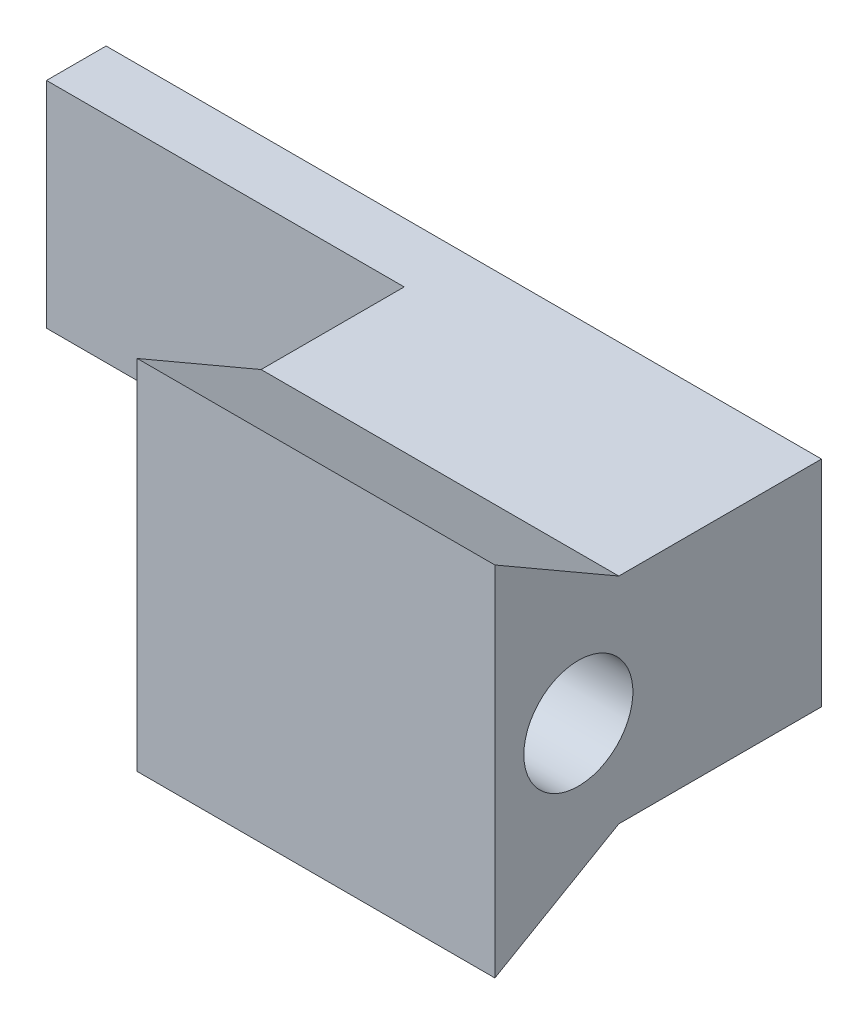
from build123d import *

# Parameters (mm, degrees)
BOSS_EXTRUDE1_DEPTH    = 3
F_00_90_TAPPED_HOLE1_D = 0.9144
SKETCH1_5_W            = 0.5
SKETCH1_5_H            = 1.8
BOSS_EXTRUDE2_DEPTH    = 3


with BuildPart() as part:
    # Sketch1 → Boss-Extrude1 (new body)
    with BuildSketch(Plane(origin=(0, 0, 0), x_dir=(0, 0, -1), z_dir=(1, 0, 0))):
        Polygon((0, 1.5), (0, -1.5), (1.039230485, -0.9), (2.739230485, -0.9), (2.739230485, 0.9), (1.039230485, 0.9), align=None)
    extrude(amount=BOSS_EXTRUDE1_DEPTH)

    # 00-90 Tapped Hole1 (through all)
    with Locations(Plane.ZY):
        with Locations((-0.7, 0)):
            Hole(F_00_90_TAPPED_HOLE1_D / 2)

    # Sketch1_5 → Boss-Extrude2 (add)
    with BuildSketch(Plane(origin=(0, 0, 0), x_dir=(0, 0, -1), z_dir=(1, 0, 0))):
        with Locations((2.489230485, 0)):
            Rectangle(SKETCH1_5_W, SKETCH1_5_H)
    extrude(amount=-BOSS_EXTRUDE2_DEPTH)


solid = part.part
